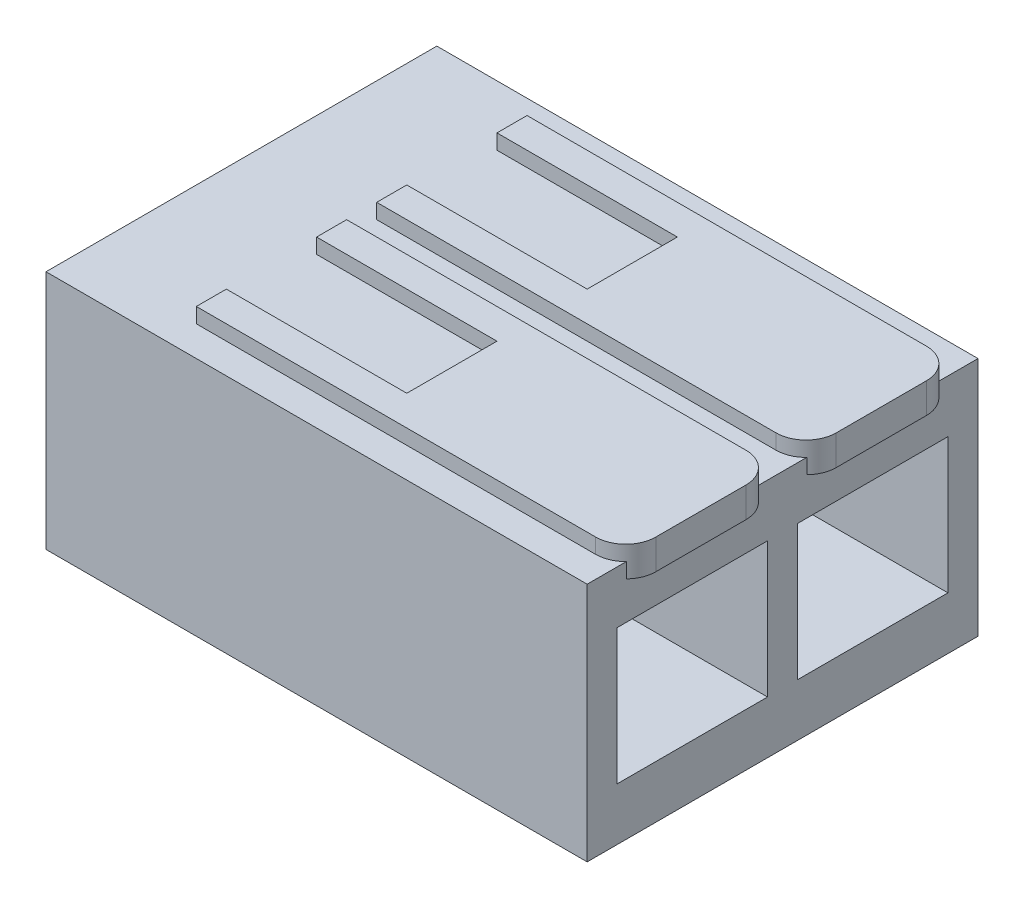
from build123d import *

# Parameters (mm, degrees)
BOSS_EXTRU_1_DEPTH      = 13
ESQUISSE4_W             = 5
ESQUISSE4_H             = 4.5
ENL_V_MAT_EXTRU_2_DEPTH = 5
BOSS_EXTRU_2_DEPTH      = 0.5
BOSS_EXTRU_2_2_DEPTH    = 0.5


with BuildPart() as part:
    # Esquisse1 → Boss.-Extru.1 (new body)
    with BuildSketch(Plane.XY):
        Polygon((0, 0), (18, 0), (18, 8), (0, 8), (0, 4), align=None)
    extrude(amount=BOSS_EXTRU_1_DEPTH)

    # Esquisse4 → Enlèv. mat.-Extru.2 (cut)
    with BuildSketch(Plane(origin=(18, 0, 0), x_dir=(0, 0, -1), z_dir=(1, 0, 0))):
        with Locations((-3.5, 4)):
            Rectangle(ESQUISSE4_W, ESQUISSE4_H)
        with Locations((-9.5, 4)):
            Rectangle(ESQUISSE4_W, ESQUISSE4_H)
    extrude(amount=-ENL_V_MAT_EXTRU_2_DEPTH, mode=Mode.SUBTRACT)


with BuildPart() as body_2:
    # Esquisse5 → Boss.-Extru.2 (new body, symmetric)
    with BuildSketch(Plane(origin=(0, 8, 0), x_dir=(1, 0, 0), z_dir=(0, 1, 0))):
        with BuildLine():
            Line((4, -1), (17.283200591, -1))
            ThreePointArc((17.283200591, -1), (17.990307373, -1.292893219), (18.283200591, -2))
            Line((18.283200591, -2), (18.283200591, -5))
            ThreePointArc((18.283200591, -5), (17.990307373, -5.707106781), (17.283200591, -6))
            Line((17.283200591, -6), (4, -6))
            Line((4, -6), (4, -5))
            Line((4, -5), (10, -5))
            Line((10, -5), (10, -2))
            Line((10, -2), (4, -2))
            Line((4, -2), (4, -1))
        make_face()
    extrude(amount=BOSS_EXTRU_2_DEPTH, both=True)


with BuildPart() as body_3:
    # Esquisse5 → Boss.-Extru.2 2 (new body, symmetric)
    with BuildSketch(Plane(origin=(0, 8, 0), x_dir=(1, 0, 0), z_dir=(0, 1, 0))):
        with BuildLine():
            Line((4, -7), (17.283200591, -7))
            ThreePointArc((17.283200591, -7), (17.990307373, -7.292893219), (18.283200591, -8))
            Line((18.283200591, -8), (18.283200591, -11))
            ThreePointArc((18.283200591, -11), (17.990307373, -11.707106781), (17.283200591, -12))
            Line((17.283200591, -12), (4, -12))
            Line((4, -12), (4, -11))
            Line((4, -11), (10, -11))
            Line((10, -11), (10, -8))
            Line((10, -8), (4, -8))
            Line((4, -8), (4, -7))
        make_face()
    extrude(amount=BOSS_EXTRU_2_2_DEPTH, both=True)


solid = Compound([part.part, body_2.part, body_3.part])
